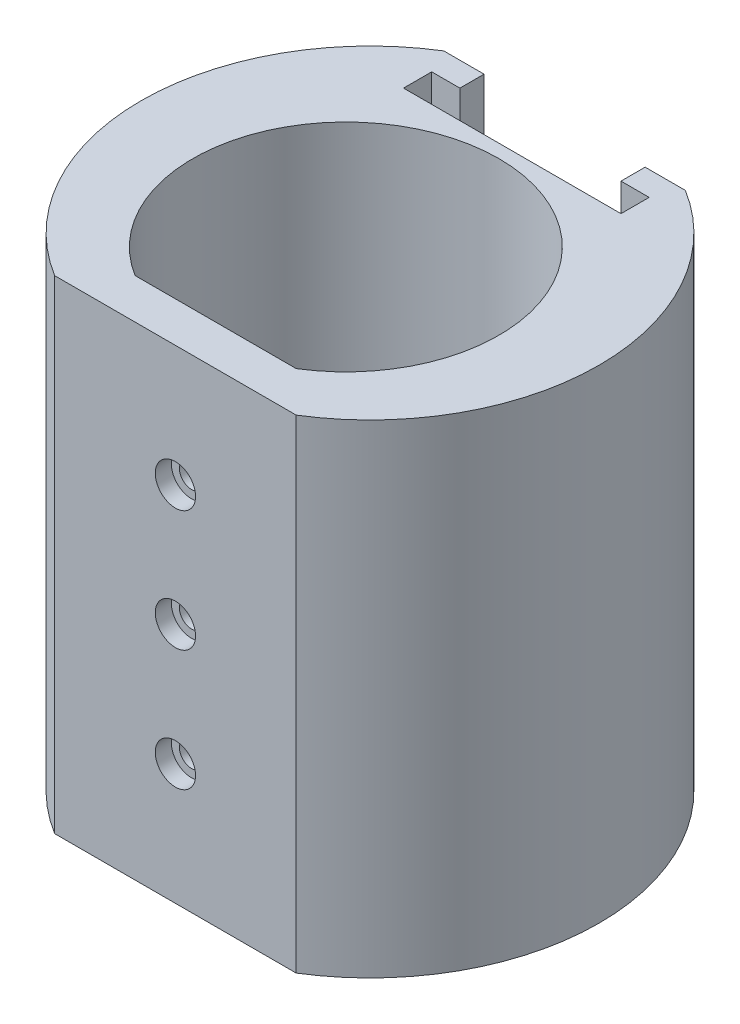
from build123d import *

# Parameters (mm, degrees)
BOSS_EXTRUDE1_DEPTH = 30
CUT_EXTRUDE1_DEPTH  = 50
SKETCH5_R           = 1.5
CUT_EXTRUDE2_DEPTH  = 5
SKETCH5_3_R         = 2.5
SKETCH5_3_R_2       = 1.5
CUT_EXTRUDE3_DEPTH  = 2
LPATTERN1_COUNT     = 2
LPATTERN1_PITCH     = 15
LPATTERN1_COL_COUNT = 2
LPATTERN1_COL_PITCH = 15


with BuildPart() as part:
    # Sketch1 → Boss-Extrude1 (new body, symmetric)
    with BuildSketch(Plane(origin=(0, 0, 0), x_dir=(1, 0, 0), z_dir=(0, 1, 0))):
        with BuildLine():
            Line((-15, -21.161374477), (15, -21.161374477))
            ThreePointArc((15, -21.161374477), (28.43891729, 3), (15, 27.161374477))
            Line((15, 27.161374477), (-15, 27.161374477))
            ThreePointArc((-15, 27.161374477), (-28.43891729, 3), (-15, -21.161374477))
        make_face()
        with BuildLine():
            Line((-10, -16.161374477), (10, -16.161374477))
            ThreePointArc((10, -16.161374477), (0, 19.005), (-10, -16.161374477))
        make_face(mode=Mode.SUBTRACT)
    extrude(amount=BOSS_EXTRUDE1_DEPTH, both=True)

    # Sketch4 → Cut-Extrude1 (cut)
    with BuildSketch(Plane(origin=(0, 30, 0), x_dir=(1, 0, 0), z_dir=(0, 1, 0))):
        Polygon((-10, 27.161374477), (-10, 24.161374477), (-13.5, 24.161374477), (-13.5, 20.661374477), (13.5, 20.661374477), (13.5, 24.161374477), (10, 24.161374477), (10, 27.161374477), align=None)
    extrude(amount=-CUT_EXTRUDE1_DEPTH, mode=Mode.SUBTRACT)

    # Sketch5 → Cut-Extrude2 (cut)
    with BuildSketch(Plane.XY.offset(21.161374477)):
        Circle(SKETCH5_R)
    cut_extrude2 = extrude(amount=-CUT_EXTRUDE2_DEPTH, mode=Mode.SUBTRACT)

    # Sketch5_3 → Cut-Extrude3 (cut)
    with BuildSketch(Plane.XY.offset(21.161374477)):
        Circle(SKETCH5_3_R)
        Circle(SKETCH5_3_R_2, mode=Mode.SUBTRACT)
    cut_extrude3 = extrude(amount=-CUT_EXTRUDE3_DEPTH, mode=Mode.SUBTRACT)

    # LPattern1: Cut-Extrude2, Cut-Extrude3 ×2
    with Locations(*[(0, -i * LPATTERN1_PITCH, 0) for i in range(1, LPATTERN1_COUNT)]):
        add(cut_extrude2, mode=Mode.SUBTRACT)
        add(cut_extrude3, mode=Mode.SUBTRACT)

    # LPattern1 col: Cut-Extrude2, Cut-Extrude3 ×2
    with Locations(*[(0, i * LPATTERN1_COL_PITCH, 0) for i in range(1, LPATTERN1_COL_COUNT)]):
        add(cut_extrude2, mode=Mode.SUBTRACT)
        add(cut_extrude3, mode=Mode.SUBTRACT)


solid = part.part
